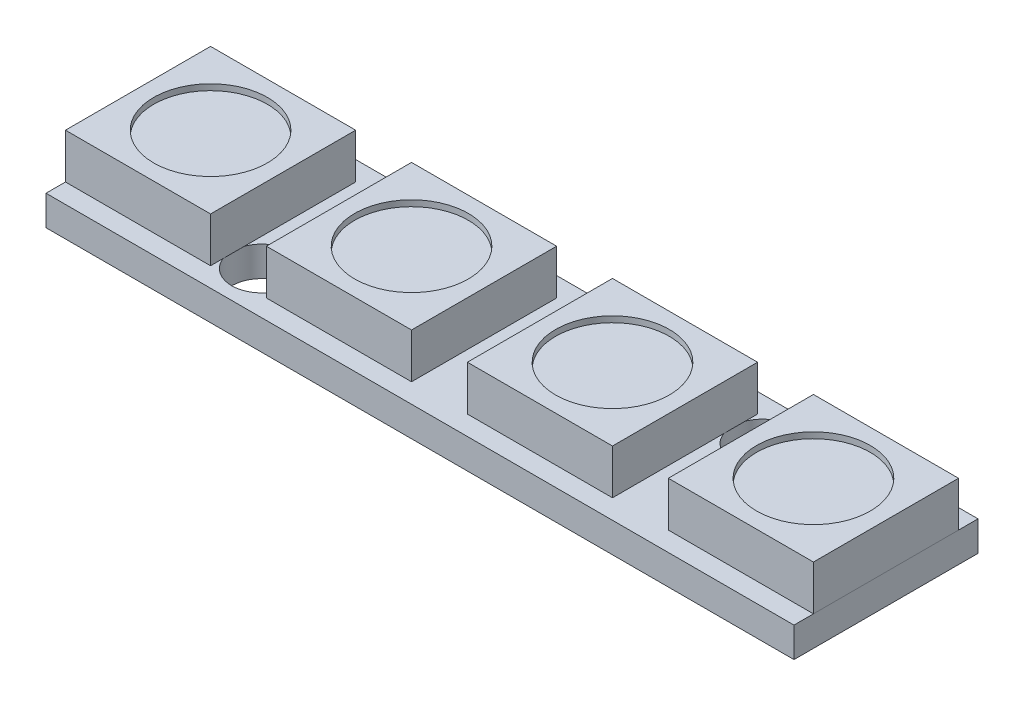
from build123d import *

# Parameters (mm, degrees)
SKETCH1_W             = 25
SKETCH1_H             = 6.15
BOSS_EXTRUDE1_DEPTH   = 1
SKETCH2_W             = 4.85
SKETCH2_H             = 4.85
BOSS_EXTRUDE2_DEPTH   = 1.5
BOSS_EXTRUDE2_2_DEPTH = 1.5
BOSS_EXTRUDE2_3_DEPTH = 1.5
BOSS_EXTRUDE2_4_DEPTH = 1.5
SKETCH3_R             = 1
CUT_EXTRUDE1_DEPTH    = 1
SKETCH4_R             = 1.9
CUT_EXTRUDE2_DEPTH    = 0.2
SKETCH5_R             = 0.8
CUT_EXTRUDE3_DEPTH    = 0.01


with BuildPart() as part:
    # Sketch1 → Boss-Extrude1 (new body)
    with BuildSketch(Plane(origin=(0, 0, 0), x_dir=(1, 0, 0), z_dir=(0, 1, 0))):
        Rectangle(SKETCH1_W, SKETCH1_H)
    extrude(amount=BOSS_EXTRUDE1_DEPTH)

    # Sketch3 → Cut-Extrude1 (cut)
    with BuildSketch(Plane(origin=(0, 1, 0), x_dir=(1, 0, 0), z_dir=(0, 1, 0))):
        with Locations((-6.716666667, -1.65)):
            Circle(SKETCH3_R)
        with Locations((6.716666667, 1.65)):
            Circle(SKETCH3_R)
    extrude(amount=-CUT_EXTRUDE1_DEPTH, mode=Mode.SUBTRACT)

    # Sketch5 → Cut-Extrude3 (cut)
    with BuildSketch(Plane.XZ):
        with Locations((0, 1.475)):
            Circle(SKETCH5_R)
        with Locations((2.54, 1.475)):
            Circle(SKETCH5_R)
        with Locations((-2.54, 1.475)):
            Circle(SKETCH5_R)
    extrude(amount=-CUT_EXTRUDE3_DEPTH, mode=Mode.SUBTRACT)


with BuildPart() as body_2:
    # Sketch2 → Boss-Extrude2 (new body)
    with BuildSketch(Plane(origin=(0, 1, 0), x_dir=(1, 0, 0), z_dir=(0, 1, 0))):
        with Locations((-3.358333333, 0)):
            Rectangle(SKETCH2_W, SKETCH2_H)
    extrude(amount=BOSS_EXTRUDE2_DEPTH)


with BuildPart() as body_3:
    # Sketch2 → Boss-Extrude2 2 (new body)
    with BuildSketch(Plane(origin=(0, 1, 0), x_dir=(1, 0, 0), z_dir=(0, 1, 0))):
        with Locations((-10.075, 0)):
            Rectangle(SKETCH2_W, SKETCH2_H)
    extrude(amount=BOSS_EXTRUDE2_2_DEPTH)


with BuildPart() as body_4:
    # Sketch2 → Boss-Extrude2 3 (new body)
    with BuildSketch(Plane(origin=(0, 1, 0), x_dir=(1, 0, 0), z_dir=(0, 1, 0))):
        with Locations((3.358333333, 0)):
            Rectangle(SKETCH2_W, SKETCH2_H)
    extrude(amount=BOSS_EXTRUDE2_3_DEPTH)


with BuildPart() as body_5:
    # Sketch2 → Boss-Extrude2 4 (new body)
    with BuildSketch(Plane(origin=(0, 1, 0), x_dir=(1, 0, 0), z_dir=(0, 1, 0))):
        with Locations((10.075, 0)):
            Rectangle(SKETCH2_W, SKETCH2_H)
    extrude(amount=BOSS_EXTRUDE2_4_DEPTH)


with BuildPart() as cut_extrude2_tool:
    # Sketch4 → Cut-Extrude2 (new body)
    with BuildSketch(Plane(origin=(0, 2.5, 0), x_dir=(1, 0, 0), z_dir=(0, 1, 0))):
        with Locations((-10.075, 0)):
            Circle(SKETCH4_R)
        with Locations((-3.358333333, 0)):
            Circle(SKETCH4_R)
        with Locations((3.358333333, 0)):
            Circle(SKETCH4_R)
        with Locations((10.075, 0)):
            Circle(SKETCH4_R)
    extrude(amount=-CUT_EXTRUDE2_DEPTH)


with BuildPart() as body_2_1:
    add(body_2.part)

    # Cut-Extrude2: cut by cut_extrude2_tool
    add(cut_extrude2_tool.part, mode=Mode.SUBTRACT)


with BuildPart() as body_3_1:
    add(body_3.part)

    # Cut-Extrude2: cut by cut_extrude2_tool
    add(cut_extrude2_tool.part, mode=Mode.SUBTRACT)


with BuildPart() as body_4_1:
    add(body_4.part)

    # Cut-Extrude2: cut by cut_extrude2_tool
    add(cut_extrude2_tool.part, mode=Mode.SUBTRACT)


with BuildPart() as body_5_1:
    add(body_5.part)

    # Cut-Extrude2: cut by cut_extrude2_tool
    add(cut_extrude2_tool.part, mode=Mode.SUBTRACT)


solid = Compound([part.part, body_2_1.part, body_3_1.part, body_4_1.part, body_5_1.part])
